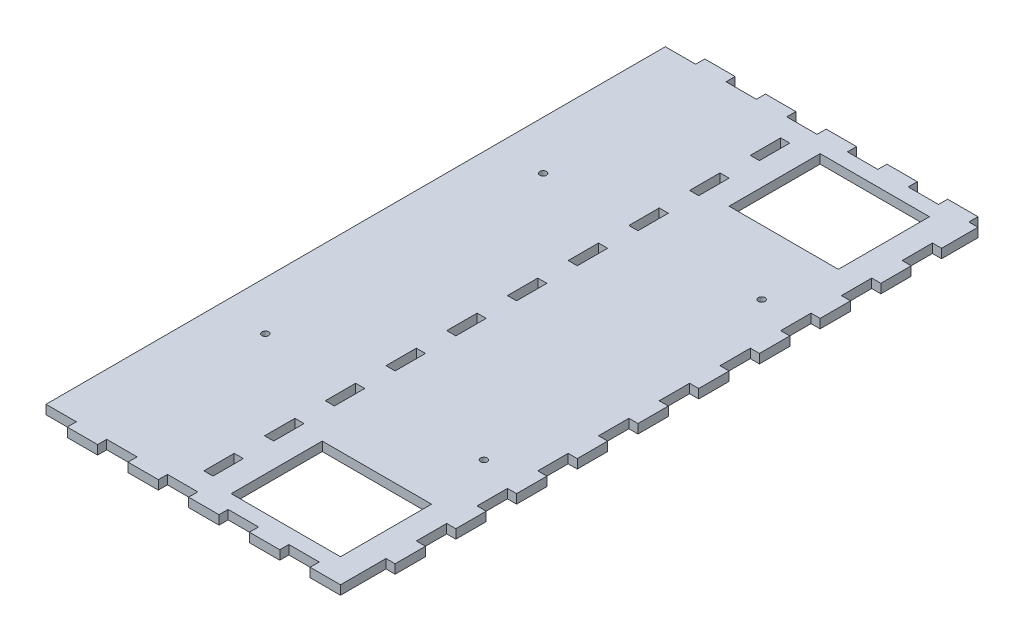
from build123d import *

# Parameters (mm, degrees)
SKETCH1_W           = 100
SKETCH1_H           = 204
BOSS_EXTRUDE1_DEPTH = 3
SKETCH2_W           = 10
SKETCH2_H           = 3
BOSS_EXTRUDE2_DEPTH = 3
LPATTERN1_COUNT     = 5
LPATTERN1_PITCH     = 20
SKETCH3_W           = 10
SKETCH3_H           = 3
BOSS_EXTRUDE3_DEPTH = 3
LPATTERN2_COUNT     = 5
LPATTERN2_PITCH     = 20
SKETCH4_W           = 3
SKETCH4_H           = 10
CUT_EXTRUDE1_DEPTH  = 4
LPATTERN3_COUNT     = 10
LPATTERN3_PITCH     = 20
SKETCH5_R           = 1.1
SKETCH5_W           = 36
SKETCH5_H           = 30
CUT_EXTRUDE2_DEPTH  = 4
SKETCH6_W           = 12
SKETCH6_H           = 3
SKETCH6_W_2         = 10
BOSS_EXTRUDE4_DEPTH = 3


with BuildPart() as part:
    # Sketch1 → Boss-Extrude1 (new body)
    with BuildSketch(Plane(origin=(0, 0, 0), x_dir=(1, 0, 0), z_dir=(0, 1, 0))):
        with Locations((50, 102)):
            Rectangle(SKETCH1_W, SKETCH1_H)
    extrude(amount=BOSS_EXTRUDE1_DEPTH)

    # Sketch2 → Boss-Extrude2 (add)
    with BuildSketch(Plane.XY):
        with Locations((95, 1.5)):
            Rectangle(SKETCH2_W, SKETCH2_H)
    boss_extrude2 = extrude(amount=BOSS_EXTRUDE2_DEPTH)

    # LPattern1: Boss-Extrude2 ×5
    with Locations(*[(-i * LPATTERN1_PITCH, 0, 0) for i in range(1, LPATTERN1_COUNT)]):
        add(boss_extrude2)

    # Sketch3 → Boss-Extrude3 (add)
    with BuildSketch(Plane(origin=(0, 0, -204), x_dir=(-1, 0, 0), z_dir=(0, 0, -1))):
        with Locations((-95, 1.5)):
            Rectangle(SKETCH3_W, SKETCH3_H)
    boss_extrude3 = extrude(amount=BOSS_EXTRUDE3_DEPTH)

    # LPattern2: Boss-Extrude3 ×5
    with Locations(*[(-i * LPATTERN2_PITCH, 0, 0) for i in range(1, LPATTERN2_COUNT)]):
        add(boss_extrude3)

    # Sketch4 → Cut-Extrude1 (cut, through all)
    with BuildSketch(Plane(origin=(0, 3, 0), x_dir=(1, 0, 0), z_dir=(0, 1, 0))):
        with Locations((46.5, 12)):
            Rectangle(SKETCH4_W, SKETCH4_H)
    cut_extrude1 = extrude(amount=-CUT_EXTRUDE1_DEPTH, mode=Mode.SUBTRACT)

    # LPattern3: Cut-Extrude1 ×10
    with Locations(*[(0, 0, -i * LPATTERN3_PITCH) for i in range(1, LPATTERN3_COUNT)]):
        add(cut_extrude1, mode=Mode.SUBTRACT)

    # Sketch5 → Cut-Extrude2 (cut, through all)
    with BuildSketch(Plane(origin=(0, 3, 0), x_dir=(1, 0, 0), z_dir=(0, 1, 0))):
        with Locations((88, 147.75)):
            Circle(SKETCH5_R)
        with Locations((88, 56.25)):
            Circle(SKETCH5_R)
        with Locations((16, 56.25)):
            Circle(SKETCH5_R)
        with Locations((16, 147.75)):
            Circle(SKETCH5_R)
        with Locations((74, 20)):
            Rectangle(SKETCH5_W, SKETCH5_H)
        with Locations((74, 184)):
            Rectangle(SKETCH5_W, SKETCH5_H)
    extrude(amount=-CUT_EXTRUDE2_DEPTH, mode=Mode.SUBTRACT)

    # Sketch6 → Boss-Extrude4 (add)
    with BuildSketch(Plane(origin=(100, 0, 0), x_dir=(0, 0, -1), z_dir=(1, 0, 0))):
        with Locations((198, 1.5)):
            Rectangle(SKETCH6_W, SKETCH6_H)
        with Locations((157, 1.5)):
            Rectangle(SKETCH6_W_2, SKETCH6_H)
        with Locations((177, 1.5)):
            Rectangle(SKETCH6_W_2, SKETCH6_H)
        with Locations((137, 1.5)):
            Rectangle(SKETCH6_W_2, SKETCH6_H)
        with Locations((117, 1.5)):
            Rectangle(SKETCH6_W_2, SKETCH6_H)
        with Locations((97, 1.5)):
            Rectangle(SKETCH6_W_2, SKETCH6_H)
        with Locations((77, 1.5)):
            Rectangle(SKETCH6_W_2, SKETCH6_H)
        with Locations((57, 1.5)):
            Rectangle(SKETCH6_W_2, SKETCH6_H)
        with Locations((37, 1.5)):
            Rectangle(SKETCH6_W_2, SKETCH6_H)
        with Locations((17, 1.5)):
            Rectangle(SKETCH6_W_2, SKETCH6_H)
    extrude(amount=BOSS_EXTRUDE4_DEPTH)


solid = part.part
